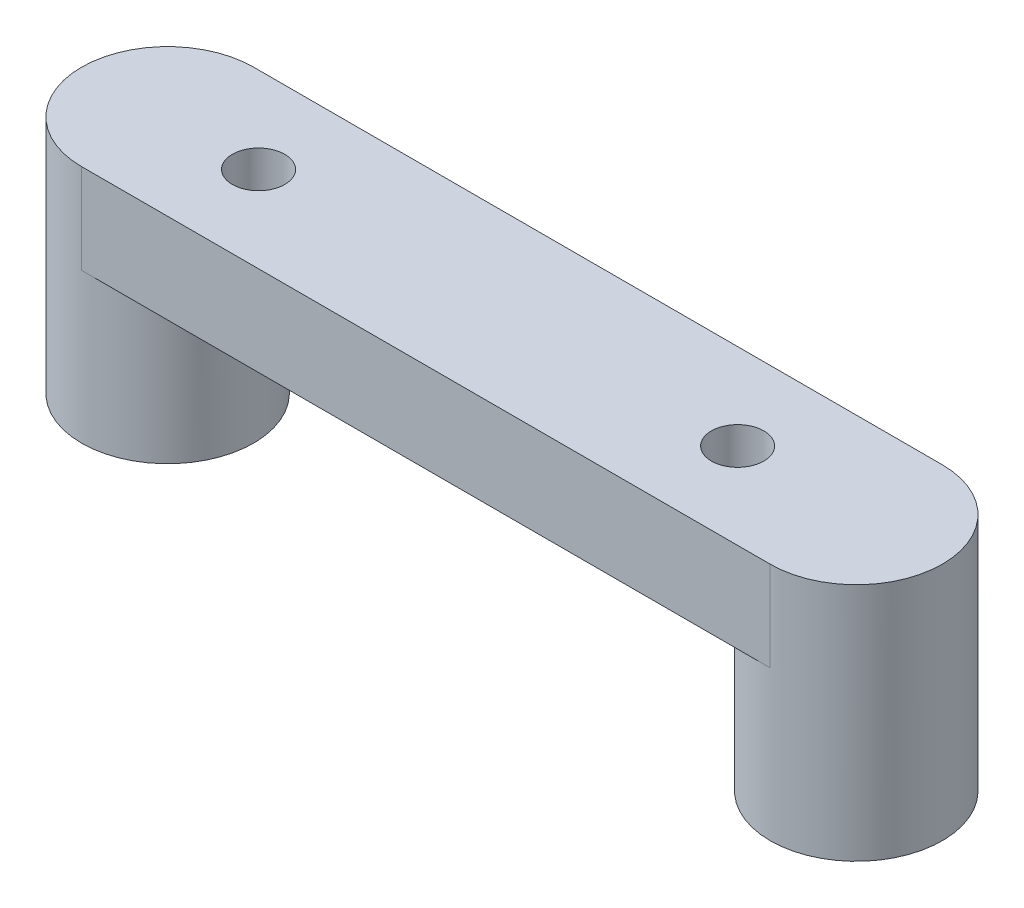
from build123d import *

# Parameters (mm, degrees)
SKETCH1_R             = 2.875
SKETCH1_R_2           = 0.875
BOSS_EXTRUDE1_DEPTH   = 5
BOSS_EXTRUDE1_2_DEPTH = 5
BOSS_EXTRUDE2_DEPTH   = 3
SKETCH3_R             = 0.875
CUT_EXTRUDE1_DEPTH    = 3


with BuildPart() as part:
    # Sketch1 → Boss-Extrude1 (new body)
    with BuildSketch(Plane(origin=(0, 0, 0), x_dir=(1, 0, 0), z_dir=(0, 1, 0))):
        with Locations((-11.5, 0)):
            Circle(SKETCH1_R)
        with Locations((-11.5, 0)):
            Circle(SKETCH1_R_2, mode=Mode.SUBTRACT)
    extrude(amount=BOSS_EXTRUDE1_DEPTH)



with BuildPart() as body_2:
    # Sketch1 → Boss-Extrude1 2 (new body)
    with BuildSketch(Plane(origin=(0, 0, 0), x_dir=(1, 0, 0), z_dir=(0, 1, 0))):
        with Locations((11.5, 0)):
            Circle(SKETCH1_R)
        with Locations((11.5, 0)):
            Circle(SKETCH1_R_2, mode=Mode.SUBTRACT)
    extrude(amount=BOSS_EXTRUDE1_2_DEPTH)


with BuildPart() as part_1:
    add(part.part)

    add(body_2.part)  # Boss-Extrude2 merges body 2
    # Sketch2 → Boss-Extrude2 (add)
    with BuildSketch(Plane(origin=(0, 5, 0), x_dir=(1, 0, 0), z_dir=(0, 1, 0))):
        with BuildLine():
            ThreePointArc((-10.625, 0), (-10.881281566, 0.618718434), (-11.5, 0.875))
            Line((-11.5, 0.875), (-11.5, -0.875))
            ThreePointArc((-11.5, -0.875), (-10.881281566, -0.618718434), (-10.625, 0))
        make_face()
        with BuildLine():
            Line((-11.5, -0.875), (-11.5, 0.875))
            ThreePointArc((-11.5, 0.875), (-12.375, 0), (-11.5, -0.875))
        make_face()
        with BuildLine():
            ThreePointArc((-8.625, 0), (-9.467068004, 2.032931996), (-11.5, 2.875))
            Line((-11.5, 2.875), (-11.5, 0.875))
            ThreePointArc((-11.5, 0.875), (-10.881281566, 0.618718434), (-10.625, 0))
            ThreePointArc((-10.625, 0), (-10.881281566, -0.618718434), (-11.5, -0.875))
            Line((-11.5, -0.875), (-11.5, -2.875))
            ThreePointArc((-11.5, -2.875), (-9.467068004, -2.032931996), (-8.625, 0))
        make_face()
        with BuildLine():
            Line((-11.5, 0.875), (-11.5, 2.875))
            ThreePointArc((-11.5, 2.875), (-14.375, 0), (-11.5, -2.875))
            Line((-11.5, -2.875), (-11.5, -0.875))
            ThreePointArc((-11.5, -0.875), (-12.375, 0), (-11.5, 0.875))
        make_face()
        with BuildLine():
            Line((11.5, 2.875), (-11.5, 2.875))
            ThreePointArc((-11.5, 2.875), (-9.467068004, 2.032931996), (-8.625, 0))
            ThreePointArc((-8.625, 0), (-9.467068004, -2.032931996), (-11.5, -2.875))
            Line((-11.5, -2.875), (11.5, -2.875))
            ThreePointArc((11.5, -2.875), (8.625, 0), (11.5, 2.875))
        make_face()
        with BuildLine():
            ThreePointArc((14.375, 0), (13.532931996, 2.032931996), (11.5, 2.875))
            Line((11.5, 2.875), (11.5, -2.875))
            ThreePointArc((11.5, -2.875), (13.532931996, -2.032931996), (14.375, 0))
        make_face()
        with BuildLine():
            Line((11.5, -2.875), (11.5, 2.875))
            ThreePointArc((11.5, 2.875), (8.625, 0), (11.5, -2.875))
        make_face()
    extrude(amount=BOSS_EXTRUDE2_DEPTH)

    # Sketch3 → Cut-Extrude1 (cut)
    with BuildSketch(Plane(origin=(0, 8, 0), x_dir=(1, 0, 0), z_dir=(0, 1, 0))):
        with Locations((-8.4626864, 0)):
            Circle(SKETCH3_R)
        with Locations((7.537175494, 0)):
            Circle(SKETCH3_R)
    extrude(amount=-CUT_EXTRUDE1_DEPTH, mode=Mode.SUBTRACT)


solid = part_1.part
